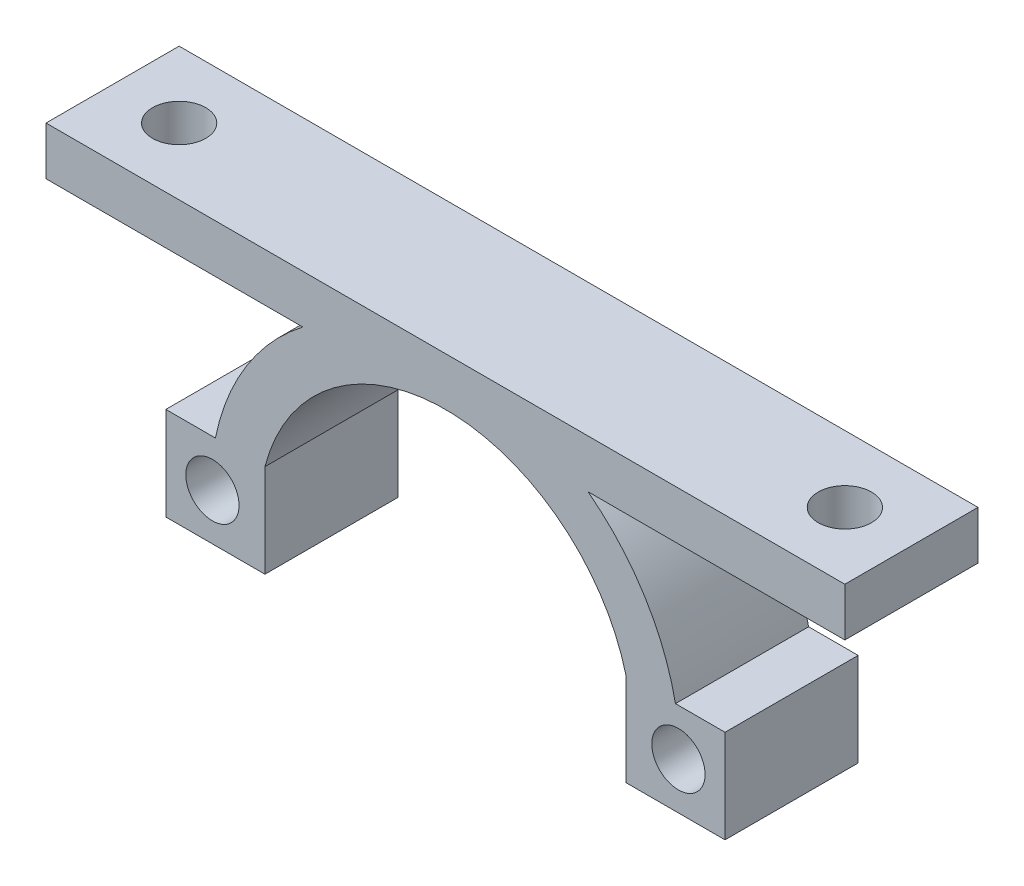
from build123d import *

# Parameters (mm, degrees)
ESQUISSE1_R             = 2
BOSS_EXTRU_1_DEPTH      = 10
ESQUISSE3_W             = 60
ESQUISSE3_H             = 3.628659563
BOSS_EXTRU_2_DEPTH      = 10
ENL_V_MAT_EXTRU_1_REACH = 23.129
ESQUISSE4_R             = 2


with BuildPart() as part:
    # Esquisse1 → Boss.-Extru.1 (new body)
    with BuildSketch(Plane.XY):
        with BuildLine():
            Line((-21, 3.5), (-21, -3.5))
            Line((-21, -3.5), (-13.555441712, -3.5))
            Line((-13.555441712, -3.5), (-13.555441712, 3.5))
            ThreePointArc((-13.555441712, 3.5), (0, 14), (13.555441712, 3.5))
            Line((13.555441712, 3.5), (13.555441712, -3.5))
            Line((13.555441712, -3.5), (21, -3.5))
            Line((21, -3.5), (21, 3.5))
            Line((21, 3.5), (17.277720856, 3.5))
            ThreePointArc((17.277720856, 3.5), (0, 17.628659563), (-17.277720856, 3.5))
            Line((-17.277720856, 3.5), (-21, 3.5))
        make_face()
        with Locations((-17.5, 0)):
            Circle(ESQUISSE1_R, mode=Mode.SUBTRACT)
        with Locations((17.5, 0)):
            Circle(ESQUISSE1_R, mode=Mode.SUBTRACT)
    extrude(amount=BOSS_EXTRU_1_DEPTH)

    # Esquisse3 → Boss.-Extru.2 (add)
    with BuildSketch(Plane.XY):
        with Locations((0, 15.814329781)):
            Rectangle(ESQUISSE3_W, ESQUISSE3_H)
    extrude(amount=BOSS_EXTRU_2_DEPTH)

    # Esquisse4 → Enlèv. mat.-Extru.1 (cut, up to next)
    with BuildSketch(Plane(origin=(0, 17.628659563, 0), x_dir=(1, 0, 0), z_dir=(0, 1, 0)), mode=Mode.PRIVATE) as enl_v_mat_extru_1_sk1:
        with Locations((-25, -5)):
            Circle(ESQUISSE4_R)
    enl_v_mat_extru_1_tool1 = extrude(enl_v_mat_extru_1_sk1.sketch, amount=-ENL_V_MAT_EXTRU_1_REACH, mode=Mode.PRIVATE) & part.part
    add(enl_v_mat_extru_1_tool1.solids().sort_by_distance((-25, 17.62866, 5))[0], mode=Mode.SUBTRACT)
    # Esquisse4 → Enlèv. mat.-Extru.1 (cut, up to next)
    with BuildSketch(Plane(origin=(0, 17.628659563, 0), x_dir=(1, 0, 0), z_dir=(0, 1, 0)), mode=Mode.PRIVATE) as enl_v_mat_extru_1_sk2:
        with Locations((25, -5)):
            Circle(ESQUISSE4_R)
    enl_v_mat_extru_1_tool2 = extrude(enl_v_mat_extru_1_sk2.sketch, amount=-ENL_V_MAT_EXTRU_1_REACH, mode=Mode.PRIVATE) & part.part
    add(enl_v_mat_extru_1_tool2.solids().sort_by_distance((25, 17.62866, 5))[0], mode=Mode.SUBTRACT)


solid = part.part
